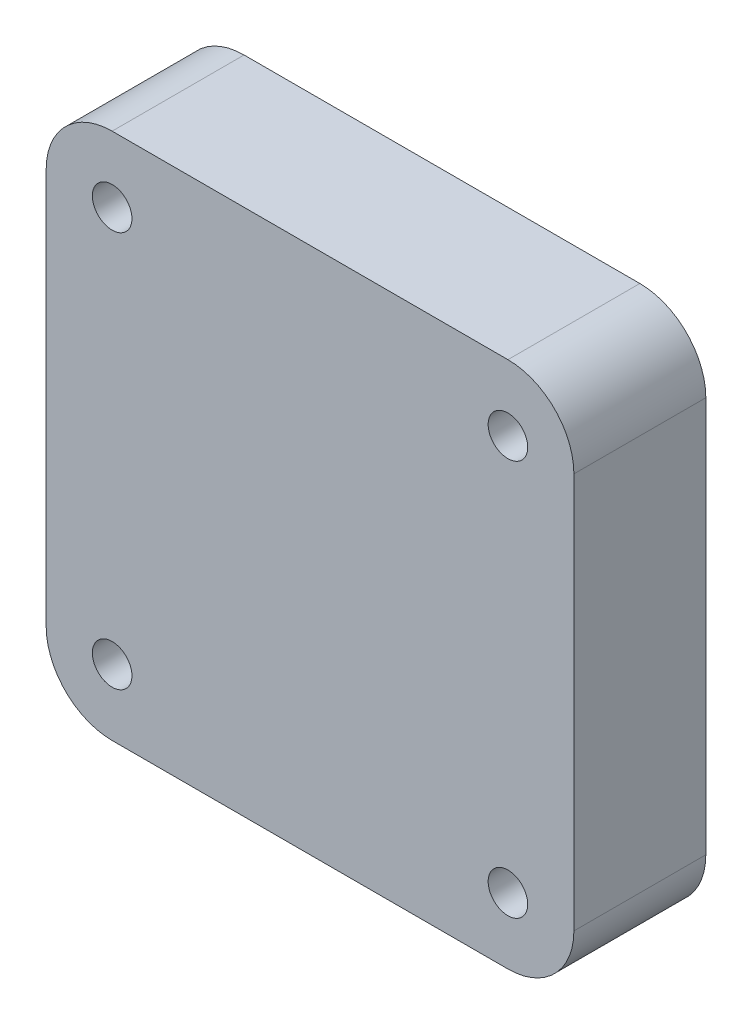
from build123d import *

# Parameters (mm, degrees)
SKETCH_1_W      = 40
SKETCH_1_H      = 40
SKETCH_1_R      = 1.5
EXTRUDE_1_DEPTH = 10
FILLET_1_R      = 5


with BuildPart() as part:
    # 草图1 → 凸台-拉伸1 (new body)
    with BuildSketch(Plane.XY):
        Rectangle(SKETCH_1_W, SKETCH_1_H)
        with Locations((-15, 15)):
            Circle(SKETCH_1_R, mode=Mode.SUBTRACT)
        with Locations((15, 15)):
            Circle(SKETCH_1_R, mode=Mode.SUBTRACT)
        with Locations((-15, -15)):
            Circle(SKETCH_1_R, mode=Mode.SUBTRACT)
        with Locations((15, -15)):
            Circle(SKETCH_1_R, mode=Mode.SUBTRACT)
    extrude(amount=EXTRUDE_1_DEPTH)

    # 圆角1
    fillet_1_edges = [part.edges().sort_by_distance(p)[0] for p in [
        (20, -20, 5),
        (-20, -20, 5),
        (-20, 20, 5),
        (20, 20, 5),
    ]]
    fillet(fillet_1_edges, radius=FILLET_1_R)


solid = part.part
